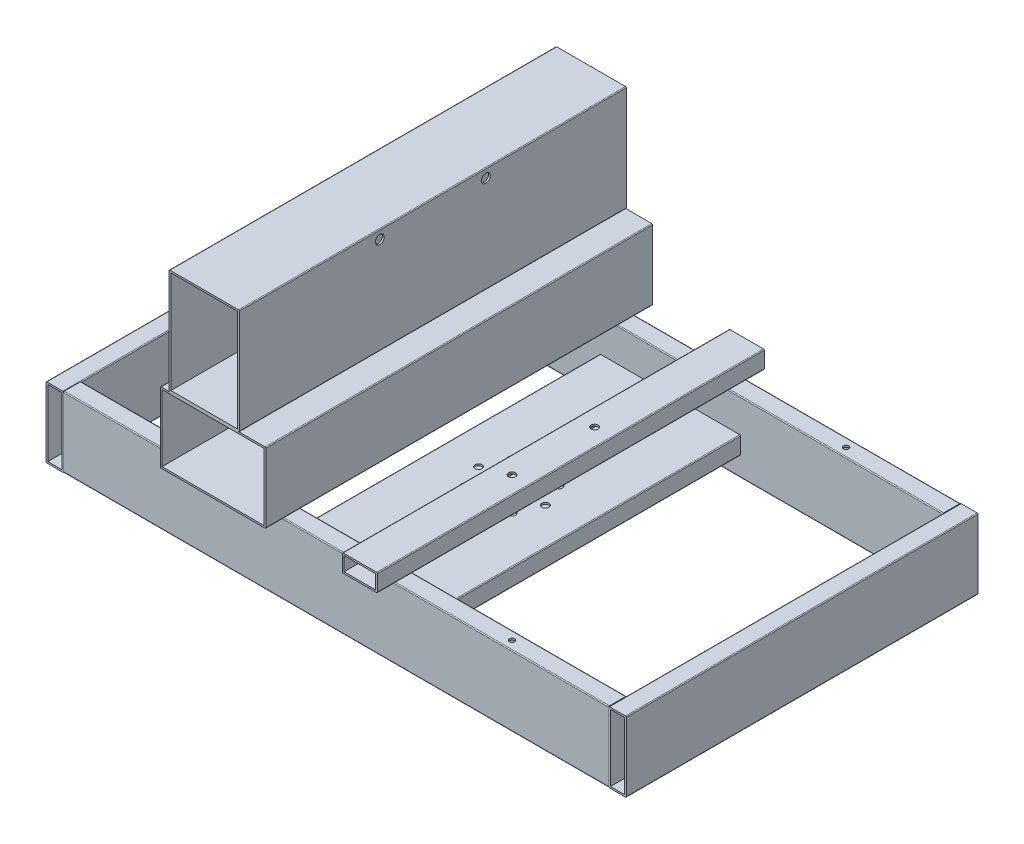
from build123d import *

# Parameters (mm, degrees)
EXTRUDE_10_DEPTH        = 100
EXTRUDE_10_DEPTH_BACK   = 100
SKETCH_1_W              = 10
SKETCH_1_H              = 40
SKETCH_1_W_2            = 8
SKETCH_1_H_2            = 38
EXTRUDE_11_DEPTH        = 100
EXTRUDE_11_DEPTH_BACK   = 100
SKETCH_14_W             = 10
SKETCH_14_H             = 40
SKETCH_14_W_2           = 8
SKETCH_14_H_2           = 38
EXTRUDE_12_DEPTH        = 154.999
EXTRUDE_12_DEPTH_BACK   = 154.999
SKETCH_15_W             = 10
SKETCH_15_H             = 40
SKETCH_15_W_2           = 8
SKETCH_15_H_2           = 38
EXTRUDE_12_2_DEPTH      = 154.999
EXTRUDE_12_2_DEPTH_BACK = 154.999
FILLET_1_R              = 0.5
FILLET_2_R              = 0.5
FILLET_3_R              = 0.5
FILLET_4_R              = 0.5
EXTRUDE_14_DEPTH        = 90
EXTRUDE_14_DEPTH_BACK   = 90
SKETCH_16_W             = 80
SKETCH_16_H             = 10
SKETCH_16_W_2           = 78
SKETCH_16_H_2           = 8
SKETCH_17_R             = 2
CUT_EXTRUDE_1_DEPTH     = 10
FILLET_5_R              = 0.5
EXTRUDE_16_DEPTH        = 110
EXTRUDE_16_DEPTH_BACK   = 110
SKETCH_19_W             = 20
SKETCH_19_H             = 10
SKETCH_19_W_2           = 18
SKETCH_19_H_2           = 8
FILLET_6_R              = 0.5
SKETCH_20_R             = 2
CUT_EXTRUDE_2_DEPTH     = 10
EXTRUDE_17_DEPTH        = 110
EXTRUDE_17_DEPTH_BACK   = 110
SKETCH_9_W              = 40
SKETCH_9_H              = 60
SKETCH_9_W_2            = 38
SKETCH_9_H_2            = 58
FILLET_7_R              = 0.5
SKETCH_22_R             = 2.5
CUT_EXTRUDE_3_DEPTH     = 40
EXTRUDE_18_DEPTH        = 110
EXTRUDE_18_DEPTH_BACK   = 110
FILLET_8_R              = 0.5
SKETCH_24_R             = 1.5
CUT_EXTRUDE_4_DEPTH     = 40


with BuildPart() as part:
    # 草图1 → 凸台-拉伸10 (new, two sides: drawn at the far end of the back side and taken through both)
    with BuildSketch(Plane.XY.offset(-EXTRUDE_10_DEPTH_BACK)):
        with Locations((108.073314483, 20)):
            Rectangle(SKETCH_1_W, SKETCH_1_H)
        with Locations((108.073314483, 20)):
            Rectangle(SKETCH_1_W_2, SKETCH_1_H_2, mode=Mode.SUBTRACT)
    extrude(amount=EXTRUDE_10_DEPTH + EXTRUDE_10_DEPTH_BACK)

    # 圆角1
    fillet_1_edges = [part.edges().sort_by_distance(p)[0] for p in [
        (103.073314483, 0, 0),
        (113.073314483, 0, 0),
        (103.073314483, 40, 0),
        (113.073314483, 40, 0),
    ]]
    fillet(fillet_1_edges, radius=FILLET_1_R)


with BuildPart() as body_2:
    # 草图14 → 凸台-拉伸11 (new, two sides: drawn at the far end of the back side and taken through both)
    with BuildSketch(Plane.XY.offset(-EXTRUDE_11_DEPTH_BACK)):
        with Locations((428.073314483, 20)):
            Rectangle(SKETCH_14_W, SKETCH_14_H)
        with Locations((428.073314483, 20)):
            Rectangle(SKETCH_14_W_2, SKETCH_14_H_2, mode=Mode.SUBTRACT)
    extrude(amount=EXTRUDE_11_DEPTH + EXTRUDE_11_DEPTH_BACK)

    # 圆角2
    fillet_2_edges = [body_2.edges().sort_by_distance(p)[0] for p in [
        (433.073314483, 0, 0),
        (433.073314483, 40, 0),
        (423.073314483, 0, 0),
        (423.073314483, 40, 0),
    ]]
    fillet(fillet_2_edges, radius=FILLET_2_R)


with BuildPart() as body_3:
    # 草图15 → 凸台-拉伸12 (new, two sides: drawn at the far end of the back side and taken through both)
    with BuildSketch(Plane(origin=(268.073314483, 0, 0), x_dir=(0, 0, -1), z_dir=(1, 0, 0)).offset(-EXTRUDE_12_DEPTH_BACK)):
        with Locations((-95, 20)):
            Rectangle(SKETCH_15_W, SKETCH_15_H)
        with Locations((-95, 20)):
            Rectangle(SKETCH_15_W_2, SKETCH_15_H_2, mode=Mode.SUBTRACT)
    extrude(amount=EXTRUDE_12_DEPTH + EXTRUDE_12_DEPTH_BACK)

    # 圆角3
    fillet_3_edges = [body_3.edges().sort_by_distance(p)[0] for p in [
        (268.073314483, 0, 90),
        (268.073314483, 0, 100),
        (268.073314483, 40, 90),
        (268.073314483, 40, 100),
    ]]
    fillet(fillet_3_edges, radius=FILLET_3_R)



with BuildPart() as body_4:
    # 草图15 → Extrude 12 2 (new, two sides: drawn at the far end of the back side and taken through both)
    with BuildSketch(Plane(origin=(268.073314483, 0, 0), x_dir=(0, 0, -1), z_dir=(1, 0, 0)).offset(-EXTRUDE_12_2_DEPTH_BACK)):
        with Locations((95, 20)):
            Rectangle(SKETCH_15_W, SKETCH_15_H)
        with Locations((95, 20)):
            Rectangle(SKETCH_15_W_2, SKETCH_15_H_2, mode=Mode.SUBTRACT)
    extrude(amount=EXTRUDE_12_2_DEPTH + EXTRUDE_12_2_DEPTH_BACK)

    # 圆角4
    fillet_4_edges = [body_4.edges().sort_by_distance(p)[0] for p in [
        (268.073314483, 0, -90),
        (268.073314483, 0, -100),
        (268.073314483, 40, -90),
        (268.073314483, 40, -100),
    ]]
    fillet(fillet_4_edges, radius=FILLET_4_R)


with BuildPart() as body_3_1:
    add(body_3.part)

    add(body_4.part)  # 凸台-拉伸14 merges body 4
    # 草图16 → 凸台-拉伸14 (add, two sides: drawn at the far end of the back side and taken through both)
    with BuildSketch(Plane.XY.offset(-EXTRUDE_14_DEPTH_BACK)):
        with Locations((268.073314483, 16)):
            Rectangle(SKETCH_16_W, SKETCH_16_H)
        with Locations((268.073314483, 16)):
            Rectangle(SKETCH_16_W_2, SKETCH_16_H_2, mode=Mode.SUBTRACT)
    extrude(amount=EXTRUDE_14_DEPTH + EXTRUDE_14_DEPTH_BACK)

    # 草图17 → 切除-拉伸1 (cut)
    with BuildSketch(Plane(origin=(0, 21, 0), x_dir=(1, 0, 0), z_dir=(0, 1, 0))):
        with Locations((268.073314483, 19)):
            Circle(SKETCH_17_R)
        with Locations((281.508343326, 13.435028843)):
            Circle(SKETCH_17_R)
        with Locations((287.073314483, 0)):
            Circle(SKETCH_17_R)
        with Locations((281.508343326, -13.435028843)):
            Circle(SKETCH_17_R)
        with Locations((268.073314483, -19)):
            Circle(SKETCH_17_R)
        with Locations((254.63828564, -13.435028843)):
            Circle(SKETCH_17_R)
        with Locations((249.073314483, 0)):
            Circle(SKETCH_17_R)
        with Locations((254.63828564, 13.435028843)):
            Circle(SKETCH_17_R)
    extrude(amount=-CUT_EXTRUDE_1_DEPTH, mode=Mode.SUBTRACT)

    # 圆角5
    fillet_5_edges = [body_3_1.edges().sort_by_distance(p)[0] for p in [
        (228.073314483, 11, 0),
        (228.073314483, 21, 0),
        (308.073314483, 11, 0),
        (308.073314483, 21, 0),
    ]]
    fillet(fillet_5_edges, radius=FILLET_5_R)

    # 草图24 → 切除-拉伸4 (cut)
    with BuildSketch(Plane(origin=(0, 40, 0), x_dir=(1, 0, 0), z_dir=(0, 1, 0))):
        with Locations((173.073314483, 95)):
            Circle(SKETCH_24_R)
        with Locations((363.073314483, 95)):
            Circle(SKETCH_24_R)
        with Locations((363.073314483, -95)):
            Circle(SKETCH_24_R)
        with Locations((173.073314483, -95)):
            Circle(SKETCH_24_R)
    extrude(amount=-CUT_EXTRUDE_4_DEPTH, mode=Mode.SUBTRACT)


with BuildPart() as body_4_2:
    # 草图19 → 凸台-拉伸16 (new, two sides: drawn at the far end of the back side and taken through both)
    with BuildSketch(Plane.XY.offset(-EXTRUDE_16_DEPTH_BACK)):
        with Locations((291.573314483, 45)):
            Rectangle(SKETCH_19_W, SKETCH_19_H)
        with Locations((291.573314483, 45)):
            Rectangle(SKETCH_19_W_2, SKETCH_19_H_2, mode=Mode.SUBTRACT)
    extrude(amount=EXTRUDE_16_DEPTH + EXTRUDE_16_DEPTH_BACK)

    # 圆角6
    fillet_6_edges = [body_4_2.edges().sort_by_distance(p)[0] for p in [
        (281.573314483, 40, 0),
        (281.573314483, 50, 0),
        (301.573314483, 40, 0),
        (301.573314483, 50, 0),
    ]]
    fillet(fillet_6_edges, radius=FILLET_6_R)

    # 草图20 → 切除-拉伸2 (cut)
    with BuildSketch(Plane(origin=(0, 50, 0), x_dir=(1, 0, 0), z_dir=(0, 1, 0))):
        with Locations((291.573314483, 23.5)):
            Circle(SKETCH_20_R)
        with Locations((291.573314483, -23.5)):
            Circle(SKETCH_20_R)
    extrude(amount=-CUT_EXTRUDE_2_DEPTH, mode=Mode.SUBTRACT)


with BuildPart() as body_5:
    # 草图9 → 凸台-拉伸17 (new, two sides: drawn at the far end of the back side and taken through both)
    with BuildSketch(Plane.XY.offset(-EXTRUDE_17_DEPTH_BACK)):
        with Locations((203.073314483, 110)):
            Rectangle(SKETCH_9_W, SKETCH_9_H)
        with Locations((203.073314483, 110)):
            Rectangle(SKETCH_9_W_2, SKETCH_9_H_2, mode=Mode.SUBTRACT)
    extrude(amount=EXTRUDE_17_DEPTH + EXTRUDE_17_DEPTH_BACK)

    # 圆角7
    fillet_7_edges = [body_5.edges().sort_by_distance(p)[0] for p in [
        (183.073314483, 140, 0),
        (183.073314483, 80, 0),
        (223.073314483, 80, 0),
        (223.073314483, 140, 0),
    ]]
    fillet(fillet_7_edges, radius=FILLET_7_R)

    # 草图22 → 切除-拉伸3 (cut)
    with BuildSketch(Plane.ZY.offset(-183.073314483)):
        with Locations((-30.15, 135)):
            Circle(SKETCH_22_R)
        with Locations((30.15, 135)):
            Circle(SKETCH_22_R)
    extrude(amount=-CUT_EXTRUDE_3_DEPTH, mode=Mode.SUBTRACT)

    # 草图23 → 凸台-拉伸18 (add, two sides: drawn at the far end of the back side and taken through both)
    with BuildSketch(Plane.XY.offset(-EXTRUDE_18_DEPTH_BACK)):
        Polygon((223.073314483, 80), (238.073314483, 80), (238.073314483, 40), (178.073314483, 40), (178.073314483, 80), align=None)
        Polygon((223.073314483, 79), (237.073314483, 79), (237.073314483, 41), (179.073314483, 41), (179.073314483, 79), align=None, mode=Mode.SUBTRACT)
    extrude(amount=EXTRUDE_18_DEPTH + EXTRUDE_18_DEPTH_BACK)

    # 圆角8
    fillet_8_edges = [body_5.edges().sort_by_distance(p)[0] for p in [
        (178.073314483, 40, 0),
        (178.073314483, 80, 0),
        (238.073314483, 40, 0),
        (238.073314483, 80, 0),
    ]]
    fillet(fillet_8_edges, radius=FILLET_8_R)


solid = Compound([part.part, body_2.part, body_3_1.part, body_4_2.part, body_5.part])
